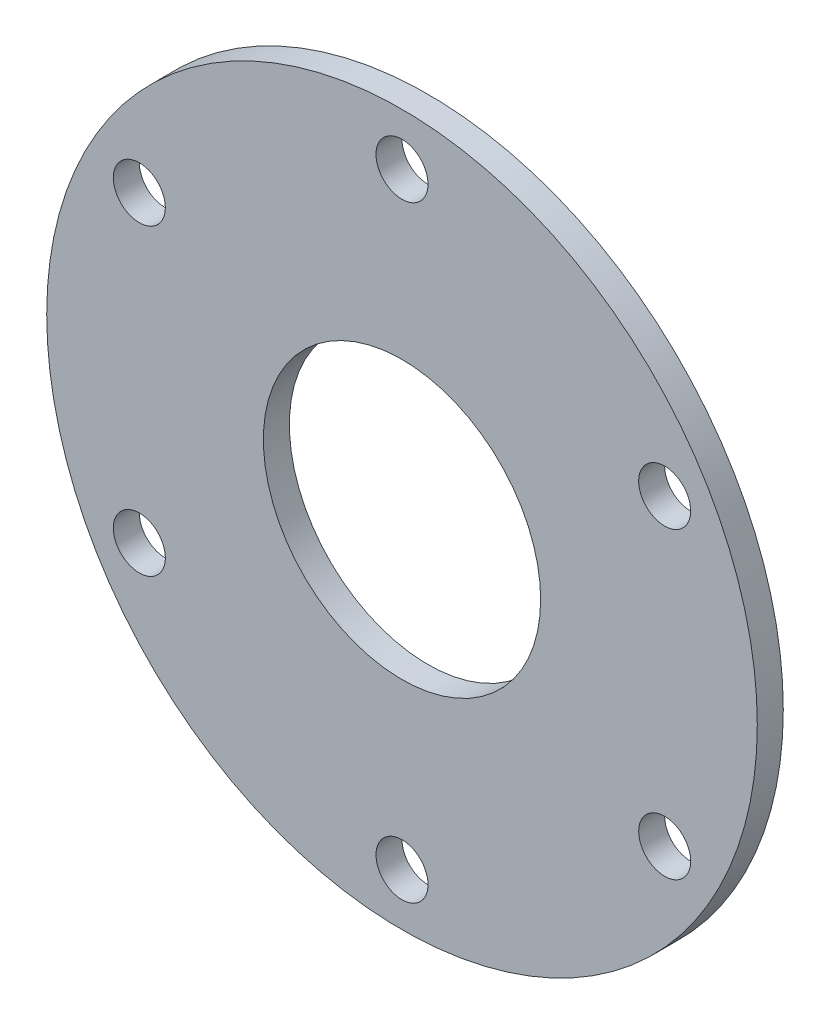
from build123d import *

# Parameters (mm, degrees)
SKETCH1_R           = 41
BOSS_EXTRUDE1_DEPTH = 3
SKETCH3_R           = 3
CUT_EXTRUDE1_DEPTH  = 4
CIRPATTERN1_COUNT   = 6
CUT_EXTRUDE2_REACH  = 5
SKETCH4_R           = 16


with BuildPart() as part:
    # Sketch1 → Boss-Extrude1 (new body)
    with BuildSketch(Plane.XY):
        Circle(SKETCH1_R)
    extrude(amount=BOSS_EXTRUDE1_DEPTH)

    # Sketch3 → Cut-Extrude1 (cut, through all)
    with BuildSketch(Plane(origin=(0, 0, 0), x_dir=(-1, 0, 0), z_dir=(0, 0, -1))):
        with Locations((0, 35)):
            Circle(SKETCH3_R)
    cut_extrude1 = extrude(amount=-CUT_EXTRUDE1_DEPTH, mode=Mode.SUBTRACT)

    # CirPattern1: Cut-Extrude1 ×6 about axis
    cirpattern1_axis = Axis((0, 0, 0), (0, 0, 1))
    for i in range(1, CIRPATTERN1_COUNT):
        add(cut_extrude1.rotate(cirpattern1_axis, i * 360 / CIRPATTERN1_COUNT), mode=Mode.SUBTRACT)

    # Sketch4 → Cut-Extrude2 (cut, up to next)
    with BuildSketch(Plane.XY.offset(3), mode=Mode.PRIVATE) as cut_extrude2_sk1:
        Circle(SKETCH4_R)
    cut_extrude2_tool1 = extrude(cut_extrude2_sk1.sketch, amount=-CUT_EXTRUDE2_REACH, mode=Mode.PRIVATE) & part.part
    add(cut_extrude2_tool1.solids().sort_by_distance((0, 0, 3))[0], mode=Mode.SUBTRACT)


solid = part.part
